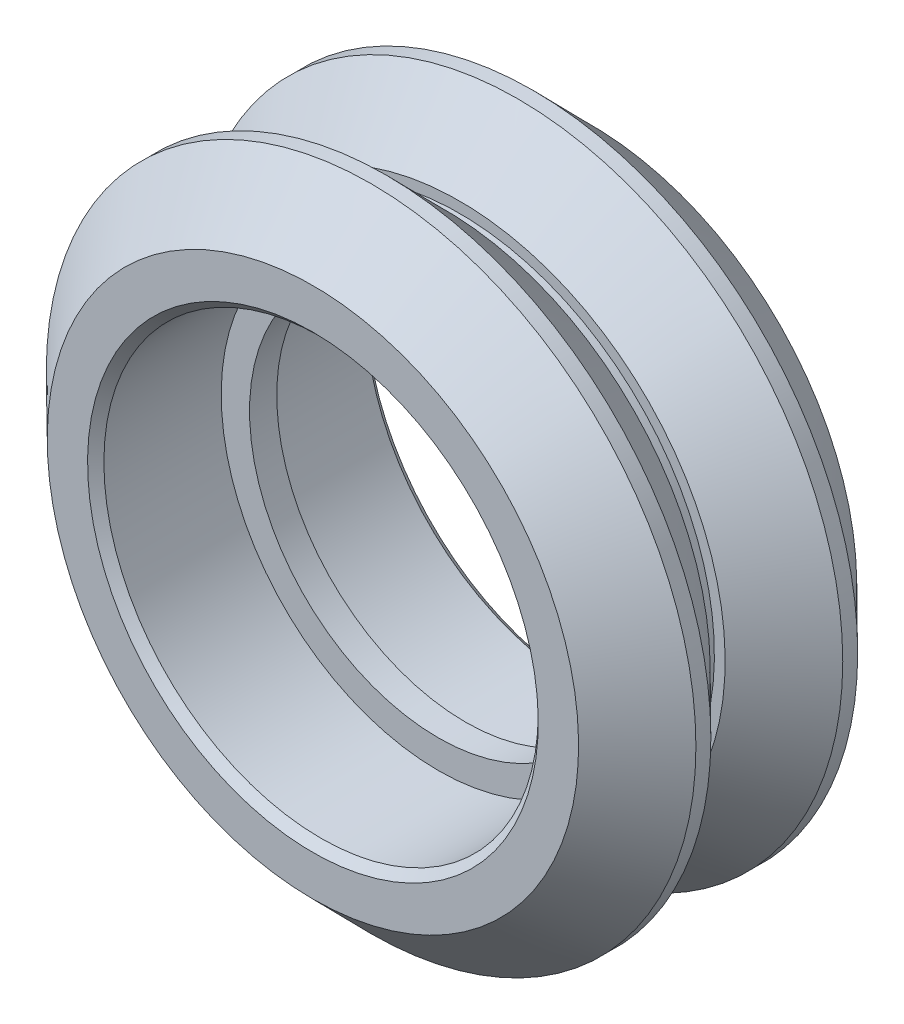
from build123d import *

# Parameters (mm, degrees)
CHAMFER1_SIZE = 0.3


with BuildPart() as part:
    # Sketch1 → Revolve1 (revolve)
    with BuildSketch(Plane(origin=(0, 0, 0), x_dir=(0, 0, -1), z_dir=(1, 0, 0))):
        Polygon((-2.975, 11.945), (-2.425, 11.945), (-0.275, 9.77), (-0.275, 9.375), (0.275, 9.375), (0.275, 9.77), (2.425, 11.945), (2.975, 11.945), (5.115, 9.77), (5.115, 7.987), (0.5, 7.987), (0.5, 6.945), (-0.5, 6.945), (-0.5, 7.987), (-5.115, 7.987), (-5.115, 9.77), align=None)
    revolve(axis=Axis((0, 0, 5.115), (0, 0, -1)))

    # Chamfer1
    chamfer1_edges = [part.edges().sort_by_distance(p)[0] for p in [
        (0, -7.987, 5.115),
        (0, -7.987, -5.115),
    ]]
    chamfer(chamfer1_edges, length=CHAMFER1_SIZE)


solid = part.part
